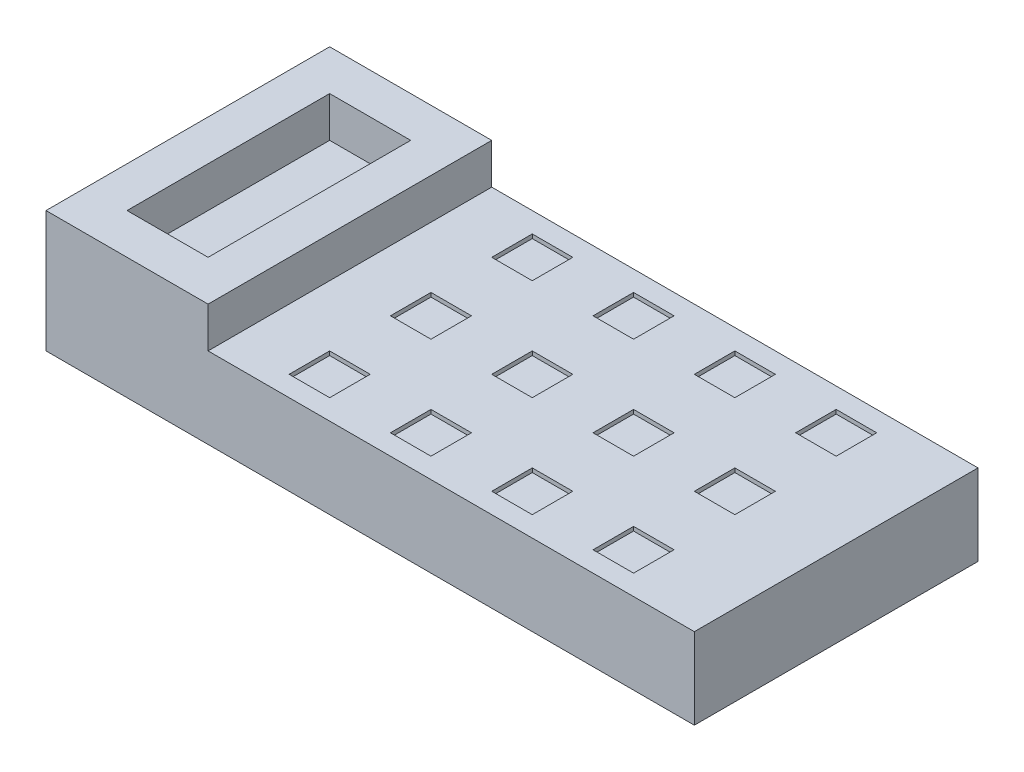
from build123d import *

# Parameters (mm, degrees)
SKETCH1_W          = 160
SKETCH1_H          = 70
EXTRUDE1_DEPTH     = 20
SKETCH2_W          = 40
SKETCH2_H          = 70
SKETCH2_W_2        = 20
SKETCH2_H_2        = 50
EXTRUDE2_DEPTH     = 10
SKETCH3_W          = 10
SKETCH3_H          = 10
CUT_EXTRUDE1_DEPTH = 1


with BuildPart() as part:
    # Sketch1 → Extrude1 (new body)
    with BuildSketch(Plane(origin=(0, 0, 0), x_dir=(1, 0, 0), z_dir=(0, 1, 0))):
        with Locations((80, 35)):
            Rectangle(SKETCH1_W, SKETCH1_H)
    extrude(amount=EXTRUDE1_DEPTH)

    # Sketch2 → Extrude2 (add)
    with BuildSketch(Plane(origin=(0, 20, 0), x_dir=(-1, 0, 0), z_dir=(0, 1, 0))):
        with Locations((-20, -35)):
            Rectangle(SKETCH2_W, SKETCH2_H)
        with Locations((-20, -35)):
            Rectangle(SKETCH2_W_2, SKETCH2_H_2, mode=Mode.SUBTRACT)
    extrude(amount=EXTRUDE2_DEPTH)

    # Sketch3 → Cut-Extrude1 (cut)
    with BuildSketch(Plane(origin=(0, 20, 0), x_dir=(-1, 0, 0), z_dir=(0, 1, 0))):
        with Locations((-110, -60)):
            Rectangle(SKETCH3_W, SKETCH3_H)
        with Locations((-110, -35)):
            Rectangle(SKETCH3_W, SKETCH3_H)
        with Locations((-135, -35)):
            Rectangle(SKETCH3_W, SKETCH3_H)
        with Locations((-60, -60)):
            Rectangle(SKETCH3_W, SKETCH3_H)
        with Locations((-60, -10)):
            Rectangle(SKETCH3_W, SKETCH3_H)
        with Locations((-135, -60)):
            Rectangle(SKETCH3_W, SKETCH3_H)
        with Locations((-135, -10)):
            Rectangle(SKETCH3_W, SKETCH3_H)
        with Locations((-110, -10)):
            Rectangle(SKETCH3_W, SKETCH3_H)
        with Locations((-85, -10)):
            Rectangle(SKETCH3_W, SKETCH3_H)
        with Locations((-85, -60)):
            Rectangle(SKETCH3_W, SKETCH3_H)
        with Locations((-60, -35)):
            Rectangle(SKETCH3_W, SKETCH3_H)
        with Locations((-85, -35)):
            Rectangle(SKETCH3_W, SKETCH3_H)
    extrude(amount=-CUT_EXTRUDE1_DEPTH, mode=Mode.SUBTRACT)


solid = part.part
